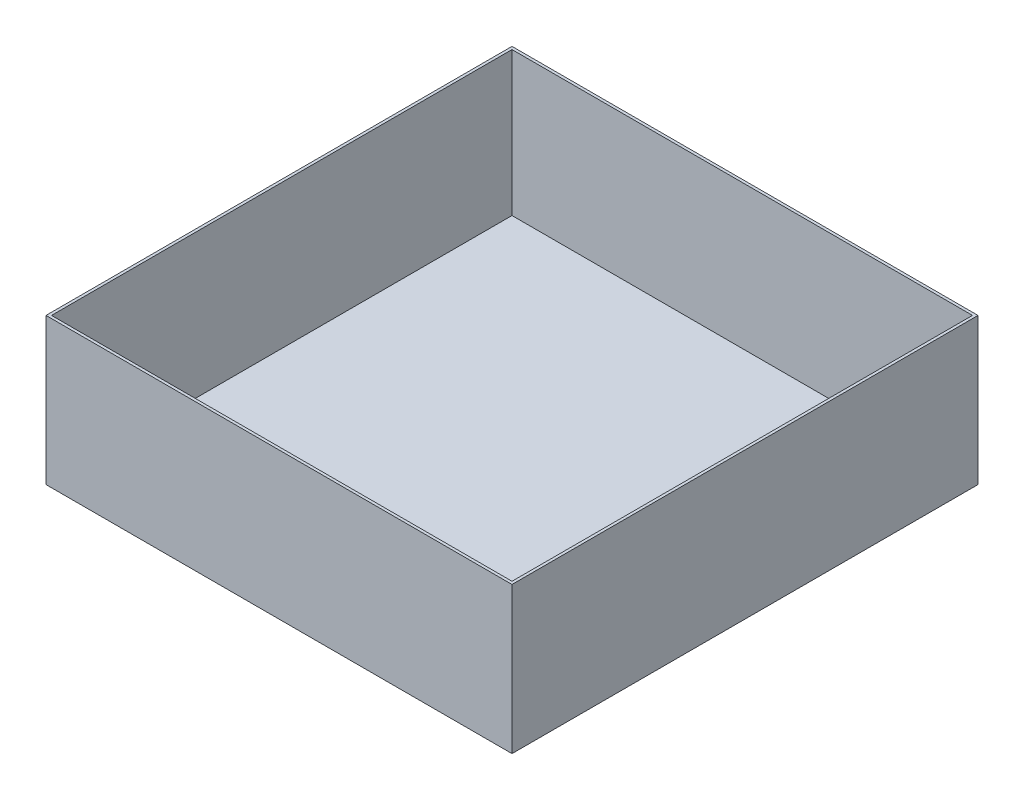
from build123d import *

# Parameters (mm, degrees)
SKETCH1_W           = 1676.4
SKETCH1_H           = 1676.4
BOSS_EXTRUDE1_DEPTH = 10
SKETCH1_2_W         = 1696.4
SKETCH1_2_H         = 1696.4
SKETCH1_2_W_2       = 1676.4
SKETCH1_2_H_2       = 1676.4
EXTRUDE_THIN1_DEPTH = 533.4


with BuildPart() as part:
    # Sketch1 → Boss-Extrude1 (new body)
    with BuildSketch(Plane(origin=(0, 0, 0), x_dir=(1, 0, 0), z_dir=(0, 1, 0))):
        Rectangle(SKETCH1_W, SKETCH1_H)
    extrude(amount=BOSS_EXTRUDE1_DEPTH)

    # Sketch1_2 → Extrude-Thin1 (add)
    with BuildSketch(Plane(origin=(0, 0, 0), x_dir=(1, 0, 0), z_dir=(0, 1, 0))):
        Rectangle(SKETCH1_2_W, SKETCH1_2_H)
        Rectangle(SKETCH1_2_W_2, SKETCH1_2_H_2, mode=Mode.SUBTRACT)
    extrude(amount=EXTRUDE_THIN1_DEPTH)


solid = part.part
